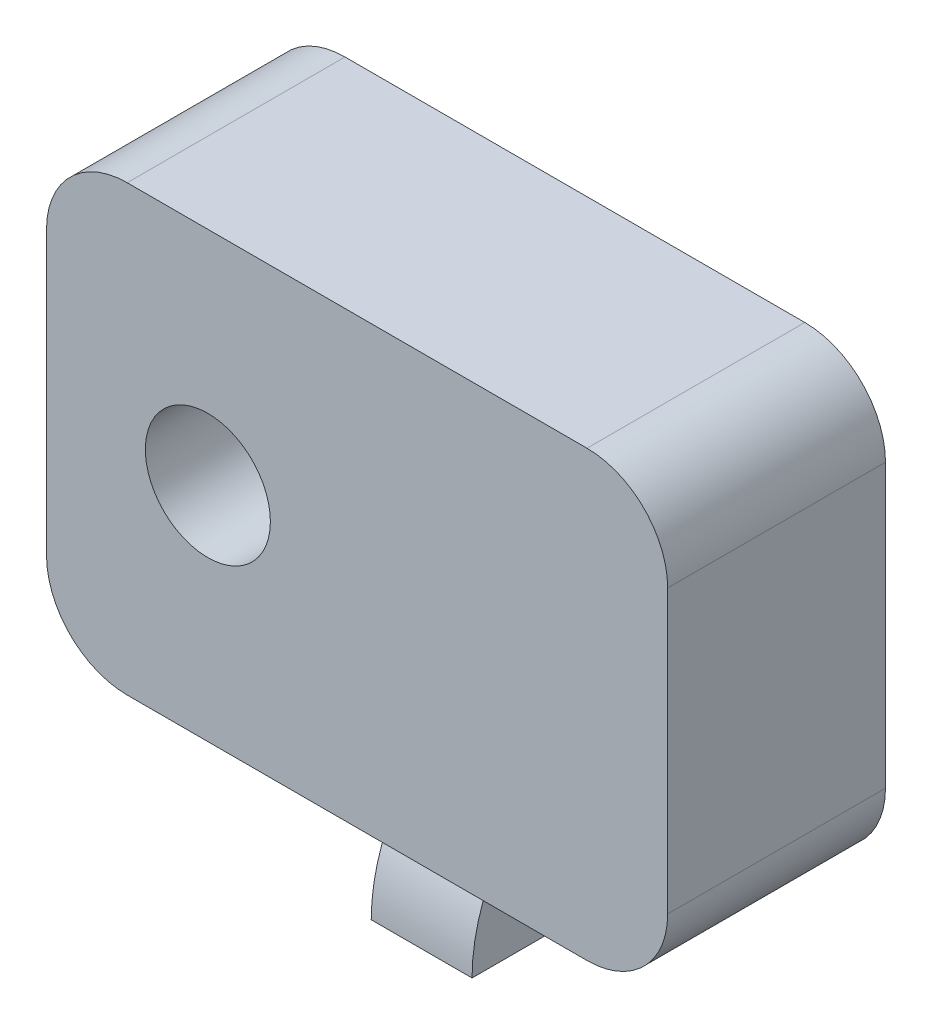
from build123d import *

# Parameters (mm, degrees)
SKETCH1_W           = 77
SKETCH1_H           = 55
BOSS_EXTRUDE1_DEPTH = 27
FILLET1_R           = 10
BOSS_EXTRUDE2_START = -44.75
BOSS_EXTRUDE2_DEPTH = 12.5
SKETCH3_R           = 7.75
CUT_EXTRUDE1_DEPTH  = 12.5


with BuildPart() as part:
    # Sketch1 → Boss-Extrude1 (new body)
    with BuildSketch(Plane.XY):
        with Locations((-38.5, 27.5)):
            Rectangle(SKETCH1_W, SKETCH1_H)
    extrude(amount=BOSS_EXTRUDE1_DEPTH)

    # Fillet1
    fillet1_edges = [part.edges().sort_by_distance(p)[0] for p in [
        (0, 0, 13.5),
        (-77, 0, 13.5),
        (-77, 55, 13.5),
        (0, 55, 13.5),
    ]]
    fillet(fillet1_edges, radius=FILLET1_R)

    # Sketch2 → Boss-Extrude2 (add)
    with BuildSketch(Plane(origin=(0, 0, 0), x_dir=(0, 0, -1), z_dir=(1, 0, 0)).offset(BOSS_EXTRUDE2_START)):
        with BuildLine():
            Line((-2, 0), (-2, -11))
            ThreePointArc((-2, -11), (-2.838969197, -16.434369418), (-8.308548919, -17))
            Line((-8.308548919, -17), (-19, -17))
            ThreePointArc((-19, -17), (-18.23654946, -11.299122875), (-16, -6))
            Line((-16, -6), (-16, 0))
            Line((-16, 0), (-2, 0))
        make_face()
        with BuildLine():
            Line((-4.740210034, -11.700555844), (-4.740210034, -14.646739817))
            ThreePointArc((-4.740210034, -14.646739817), (-7.840210034, -13.17364783), (-4.740210034, -11.700555844))
        make_face(mode=Mode.SUBTRACT)
    extrude(amount=BOSS_EXTRUDE2_DEPTH)

    # Sketch3 → Cut-Extrude1 (cut)
    with BuildSketch(Plane.XY.offset(27)):
        with Locations((-57, 27.5)):
            Circle(SKETCH3_R)
    extrude(amount=-CUT_EXTRUDE1_DEPTH, mode=Mode.SUBTRACT)


solid = part.part
